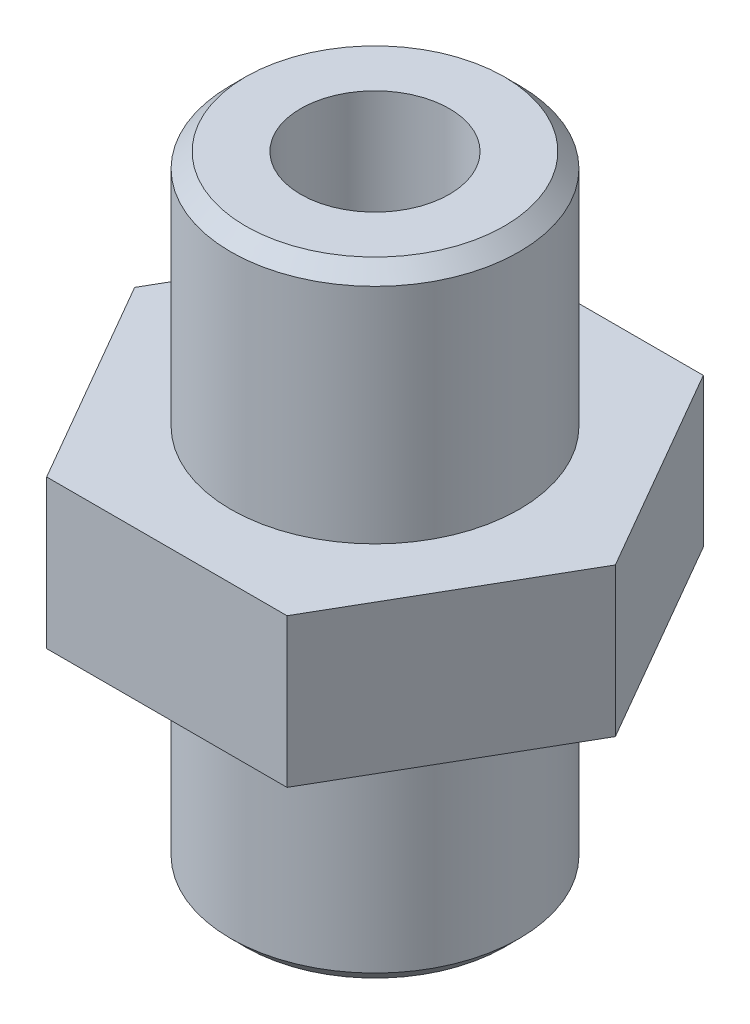
from build123d import *

# Parameters (mm, degrees)
BOSS_EXTRUDE1_DEPTH = 5
SKETCH2_R           = 4.85
BOSS_EXTRUDE2_DEPTH = 8
SKETCH3_R           = 4.85
BOSS_EXTRUDE3_DEPTH = 8
CHAMFER1_SIZE       = 0.5
SKETCH4_R           = 2.5
CUT_EXTRUDE1_DEPTH  = 22


with BuildPart() as part:
    # Sketch1 → Boss-Extrude1 (new body)
    with BuildSketch(Plane(origin=(0, 0, 0), x_dir=(1, 0, 0), z_dir=(0, 1, 0))):
        Polygon((4.041451884, -7), (8.082903769, 0), (4.041451884, 7), (-4.041451884, 7), (-8.082903769, 0), (-4.041451884, -7), align=None)
    extrude(amount=BOSS_EXTRUDE1_DEPTH)

    # Sketch2 → Boss-Extrude2 (add)
    with BuildSketch(Plane(origin=(0, 5, 0), x_dir=(1, 0, 0), z_dir=(0, 1, 0))):
        Circle(SKETCH2_R)
    extrude(amount=BOSS_EXTRUDE2_DEPTH)

    # Sketch3 → Boss-Extrude3 (add)
    with BuildSketch(Plane.XZ):
        Circle(SKETCH3_R)
    extrude(amount=BOSS_EXTRUDE3_DEPTH)

    # Chamfer1
    chamfer1_edges = [part.edges().sort_by_distance(p)[0] for p in [
        (-4.85, 13, 0),
        (-4.85, -8, 0),
    ]]
    chamfer(chamfer1_edges, length=CHAMFER1_SIZE)

    # Sketch4 → Cut-Extrude1 (cut, through all)
    with BuildSketch(Plane(origin=(0, 13, 0), x_dir=(1, 0, 0), z_dir=(0, 1, 0))):
        Circle(SKETCH4_R)
    extrude(amount=-CUT_EXTRUDE1_DEPTH, mode=Mode.SUBTRACT)


solid = part.part
